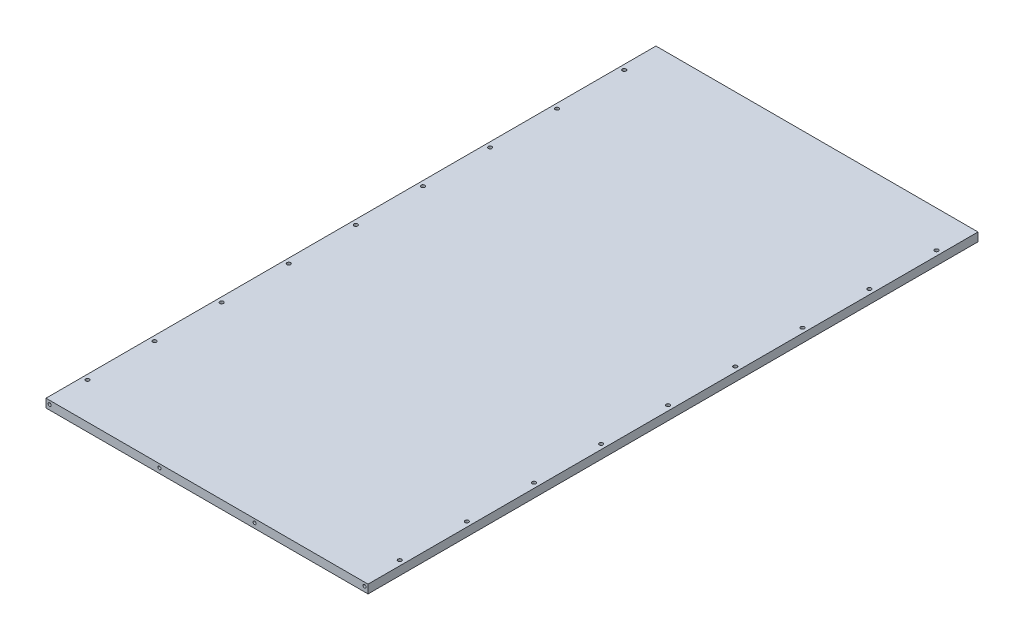
from build123d import *

# Parameters (mm, degrees)
SKETCH1_W                      = 264
SKETCH1_H                      = 500
BOSS_EXTRUDE1_DEPTH            = 7
CUT_EXTRUDE1_DEPTH             = 1
F_3_0MM_DOWEL_HOLE1_AT_2_COUNT = 2
F_3_0MM_DOWEL_HOLE1_AT_2_PITCH = 55
F_3_0MM_DOWEL_HOLE1_AT_3_COUNT = 2
F_3_0MM_DOWEL_HOLE1_AT_3_PITCH = 110
F_3_0MM_DOWEL_HOLE1_AT_4_COUNT = 2
F_3_0MM_DOWEL_HOLE1_AT_4_PITCH = 165
F_3_0MM_DOWEL_HOLE1_AT_5_COUNT = 2
F_3_0MM_DOWEL_HOLE1_AT_5_PITCH = 220
CUT_EXTRUDE2_DEPTH             = 6
FILLET1_R                      = 4
M3_TAPPED_HOLE2_D              = 2.5
M3_TAPPED_HOLE2_DEPTH          = 7.5
M3_TAPPED_HOLE2_TIP            = 0.751075774


with BuildPart() as part:
    # Sketch1 → Boss-Extrude1 (new body)
    with BuildSketch(Plane(origin=(0, 0, 0), x_dir=(1, 0, 0), z_dir=(0, 1, 0))):
        Rectangle(SKETCH1_W, SKETCH1_H)
    extrude(amount=BOSS_EXTRUDE1_DEPTH)

    # Sketch2 → Cut-Extrude1 (cut)
    with BuildSketch(Plane.XZ):
        with BuildLine():
            Line((123, 230), (123, -230))
            ThreePointArc((123, -230), (119.778174593, -237.778174593), (112, -241))
            Line((112, -241), (-112, -241))
            ThreePointArc((-112, -241), (-119.778174593, -237.778174593), (-123, -230))
            Line((-123, -230), (-123, 230))
            ThreePointArc((-123, 230), (-119.778174593, 237.778174593), (-112, 241))
            Line((-112, 241), (112, 241))
            ThreePointArc((112, 241), (119.778174593, 237.778174593), (123, 230))
        make_face()
        with BuildLine():
            Line((121, 230), (121, -230))
            ThreePointArc((121, -230), (118.363961031, -236.363961031), (112, -239))
            Line((112, -239), (-112, -239))
            ThreePointArc((-112, -239), (-118.363961031, -236.363961031), (-121, -230))
            Line((-121, -230), (-121, 230))
            ThreePointArc((-121, 230), (-118.363961031, 236.363961031), (-112, 239))
            Line((-112, 239), (112, 239))
            ThreePointArc((112, 239), (118.363961031, 236.363961031), (121, 230))
        make_face(mode=Mode.SUBTRACT)
    extrude(amount=-CUT_EXTRUDE1_DEPTH, mode=Mode.SUBTRACT)

    # Sketch3 → Ø3.0mm Dowel Hole1 (revolve, cut)
    with BuildSketch(Plane(origin=(128, 7, 220), x_dir=(0, 0, 1), z_dir=(1, 0, 0))):
        Polygon((0, 0), (0, 15.901290929), (1.5, 15), (1.5, 0), align=None)
    f_3_0mm_dowel_hole1 = revolve(axis=Axis((128, 13.35, 220), (0, -1, 0)), mode=Mode.SUBTRACT)

    # Ø3.0mm Dowel Hole1 at 2: Ø3.0mm Dowel Hole1 ×2
    with Locations(*[(0, 0, -i * F_3_0MM_DOWEL_HOLE1_AT_2_PITCH) for i in range(1, F_3_0MM_DOWEL_HOLE1_AT_2_COUNT)]):
        add(f_3_0mm_dowel_hole1, mode=Mode.SUBTRACT)

    # Ø3.0mm Dowel Hole1 at 3: Ø3.0mm Dowel Hole1 ×2
    with Locations(*[(0, 0, -i * F_3_0MM_DOWEL_HOLE1_AT_3_PITCH) for i in range(1, F_3_0MM_DOWEL_HOLE1_AT_3_COUNT)]):
        add(f_3_0mm_dowel_hole1, mode=Mode.SUBTRACT)

    # Ø3.0mm Dowel Hole1 at 4: Ø3.0mm Dowel Hole1 ×2
    with Locations(*[(0, 0, -i * F_3_0MM_DOWEL_HOLE1_AT_4_PITCH) for i in range(1, F_3_0MM_DOWEL_HOLE1_AT_4_COUNT)]):
        add(f_3_0mm_dowel_hole1, mode=Mode.SUBTRACT)

    # Ø3.0mm Dowel Hole1 at 5: Ø3.0mm Dowel Hole1 ×2
    with Locations(*[(0, 0, -i * F_3_0MM_DOWEL_HOLE1_AT_5_PITCH) for i in range(1, F_3_0MM_DOWEL_HOLE1_AT_5_COUNT)]):
        add(f_3_0mm_dowel_hole1, mode=Mode.SUBTRACT)

    # Mirror1: Ø3.0mm Dowel Hole1 across plane
    add(f_3_0mm_dowel_hole1.mirror(Plane.XY), mode=Mode.SUBTRACT)

    # Mirror1 copy 1 sketch → Mirror1 copy 1 (revolve, cut)
    with BuildSketch(Plane(origin=(128, 7, -165), x_dir=(0, 0, -1), z_dir=(1, 0, 0))):
        Polygon((0, 0), (0, -15.901290929), (1.5, -15), (1.5, 0), align=None)
    revolve(axis=Axis((128, 13.35, -165), (0, 1, 0)), mode=Mode.SUBTRACT)

    # Mirror1 copy 2 sketch → Mirror1 copy 2 (revolve, cut)
    with BuildSketch(Plane(origin=(128, 7, -110), x_dir=(0, 0, -1), z_dir=(1, 0, 0))):
        Polygon((0, 0), (0, -15.901290929), (1.5, -15), (1.5, 0), align=None)
    revolve(axis=Axis((128, 13.35, -110), (0, 1, 0)), mode=Mode.SUBTRACT)

    # Mirror1 copy 3 sketch → Mirror1 copy 3 (revolve, cut)
    with BuildSketch(Plane(origin=(128, 7, -55), x_dir=(0, 0, -1), z_dir=(1, 0, 0))):
        Polygon((0, 0), (0, -15.901290929), (1.5, -15), (1.5, 0), align=None)
    revolve(axis=Axis((128, 13.35, -55), (0, 1, 0)), mode=Mode.SUBTRACT)

    # Mirror1 copy 4 sketch → Mirror1 copy 4 (revolve, cut)
    with BuildSketch(Plane(origin=(128, 7, 0), x_dir=(0, 0, -1), z_dir=(1, 0, 0))):
        Polygon((0, 0), (0, -15.901290929), (1.5, -15), (1.5, 0), align=None)
    revolve(axis=Axis((128, 13.35, 0), (0, 1, 0)), mode=Mode.SUBTRACT)

    # Mirror2: Ø3.0mm Dowel Hole1 across plane
    add(f_3_0mm_dowel_hole1.mirror(Plane(origin=(0, 0, 0), x_dir=(0, 0, 1), z_dir=(1, 0, 0))), mode=Mode.SUBTRACT)

    # Mirror2 copy 1 sketch → Mirror2 copy 1 (revolve, cut)
    with BuildSketch(Plane(origin=(-128, 7, -220), x_dir=(0, 0, -1), z_dir=(-1, 0, 0))):
        Polygon((0, 0), (0, 15.901290929), (1.5, 15), (1.5, 0), align=None)
    revolve(axis=Axis((-128, 13.35, -220), (0, -1, 0)), mode=Mode.SUBTRACT)

    # Mirror2 copy 2 sketch → Mirror2 copy 2 (revolve, cut)
    with BuildSketch(Plane(origin=(-128, 7, -165), x_dir=(0, 0, -1), z_dir=(-1, 0, 0))):
        Polygon((0, 0), (0, 15.901290929), (1.5, 15), (1.5, 0), align=None)
    revolve(axis=Axis((-128, 13.35, -165), (0, -1, 0)), mode=Mode.SUBTRACT)

    # Mirror2 copy 3 sketch → Mirror2 copy 3 (revolve, cut)
    with BuildSketch(Plane(origin=(-128, 7, -110), x_dir=(0, 0, -1), z_dir=(-1, 0, 0))):
        Polygon((0, 0), (0, 15.901290929), (1.5, 15), (1.5, 0), align=None)
    revolve(axis=Axis((-128, 13.35, -110), (0, -1, 0)), mode=Mode.SUBTRACT)

    # Mirror2 copy 4 sketch → Mirror2 copy 4 (revolve, cut)
    with BuildSketch(Plane(origin=(-128, 7, -55), x_dir=(0, 0, -1), z_dir=(-1, 0, 0))):
        Polygon((0, 0), (0, 15.901290929), (1.5, 15), (1.5, 0), align=None)
    revolve(axis=Axis((-128, 13.35, -55), (0, -1, 0)), mode=Mode.SUBTRACT)

    # Mirror2 copy 5 sketch → Mirror2 copy 5 (revolve, cut)
    with BuildSketch(Plane(origin=(-128, 7, 0), x_dir=(0, 0, -1), z_dir=(-1, 0, 0))):
        Polygon((0, 0), (0, 15.901290929), (1.5, 15), (1.5, 0), align=None)
    revolve(axis=Axis((-128, 13.35, 0), (0, -1, 0)), mode=Mode.SUBTRACT)

    # Mirror2 copy 6 sketch → Mirror2 copy 6 (revolve, cut)
    with BuildSketch(Plane(origin=(-128, 7, 165), x_dir=(0, 0, 1), z_dir=(-1, 0, 0))):
        Polygon((0, 0), (0, -15.901290929), (1.5, -15), (1.5, 0), align=None)
    revolve(axis=Axis((-128, 13.35, 165), (0, 1, 0)), mode=Mode.SUBTRACT)

    # Mirror2 copy 7 sketch → Mirror2 copy 7 (revolve, cut)
    with BuildSketch(Plane(origin=(-128, 7, 110), x_dir=(0, 0, 1), z_dir=(-1, 0, 0))):
        Polygon((0, 0), (0, -15.901290929), (1.5, -15), (1.5, 0), align=None)
    revolve(axis=Axis((-128, 13.35, 110), (0, 1, 0)), mode=Mode.SUBTRACT)

    # Mirror2 copy 8 sketch → Mirror2 copy 8 (revolve, cut)
    with BuildSketch(Plane(origin=(-128, 7, 55), x_dir=(0, 0, 1), z_dir=(-1, 0, 0))):
        Polygon((0, 0), (0, -15.901290929), (1.5, -15), (1.5, 0), align=None)
    revolve(axis=Axis((-128, 13.35, 55), (0, 1, 0)), mode=Mode.SUBTRACT)

    # Mirror2 copy 9 sketch → Mirror2 copy 9 (revolve, cut)
    with BuildSketch(Plane(origin=(-128, 7, 0), x_dir=(0, 0, 1), z_dir=(-1, 0, 0))):
        Polygon((0, 0), (0, -15.901290929), (1.5, -15), (1.5, 0), align=None)
    revolve(axis=Axis((-128, 13.35, 0), (0, 1, 0)), mode=Mode.SUBTRACT)

    # Sketch5 → Cut-Extrude2 (cut)
    with BuildSketch(Plane(origin=(0, 0, 0), x_dir=(-1, 0, 0), z_dir=(0, -1, 0))):
        Polygon((112, -230), (-112, -230), (112, -10), align=None)
        Polygon((97.728720398, -10), (-112, -215.983564676), (-112, -10), align=None)
        Polygon((-112, 10), (97.728720398, 10), (-112, 215.983564676), align=None)
        Polygon((112, 10), (112, 230), (-112, 230), align=None)
    extrude(amount=-CUT_EXTRUDE2_DEPTH, mode=Mode.SUBTRACT)

    # Fillet1
    fillet1_edges = [part.edges().sort_by_distance(p)[0] for p in [
        (-112, 3, 10),
        (-112, 3, 230),
        (112, 3, 230),
        (112, 3, 10),
        (-97.728720398, 3, 10),
        (112, 3, 215.983564676),
        (112, 3, -10),
        (112, 3, -215.983564676),
        (-97.728720398, 3, -10),
        (-112, 3, -10),
        (112, 3, -230),
        (-112, 3, -230),
    ]]
    fillet(fillet1_edges, radius=FILLET1_R)

    # M3 Tapped Hole2
    with Locations(Plane.XY.offset(250)):
        with Locations((-129, 4), (-39, 4), (39, 4), (129, 4)):
            Hole(M3_TAPPED_HOLE2_D / 2, depth=M3_TAPPED_HOLE2_DEPTH)
            with Locations((0, 0, -(M3_TAPPED_HOLE2_DEPTH + M3_TAPPED_HOLE2_TIP / 2))):  # 118° drill point
                Cone(0, M3_TAPPED_HOLE2_D / 2, M3_TAPPED_HOLE2_TIP, mode=Mode.SUBTRACT)


solid = part.part
